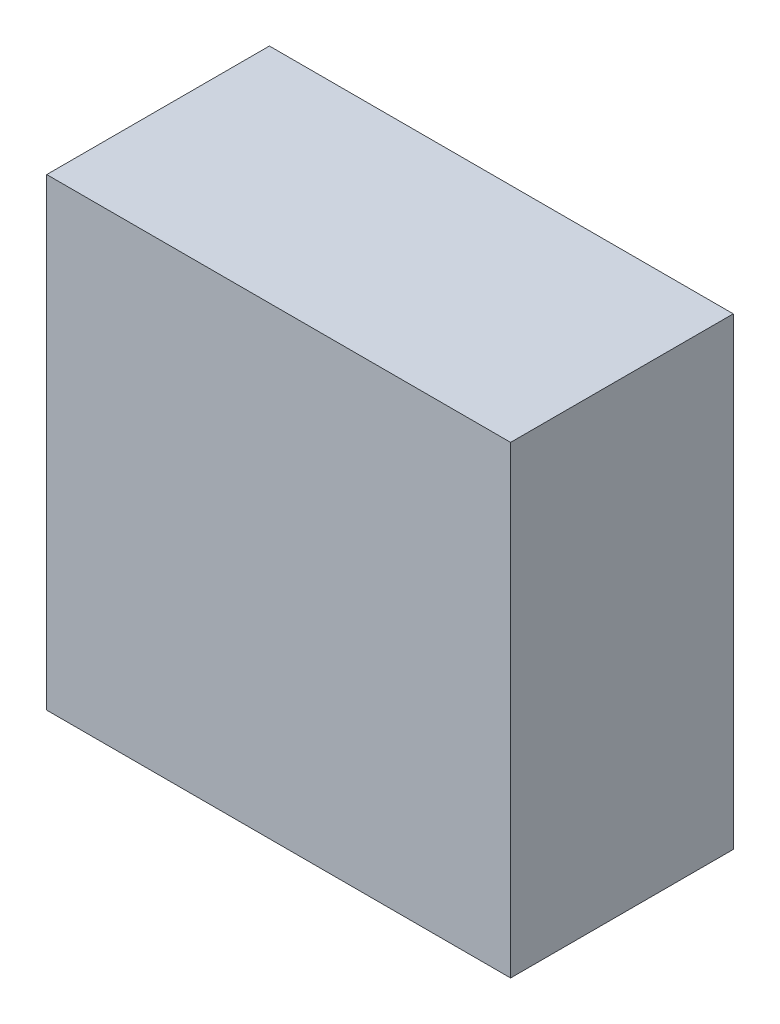
from build123d import *

# Parameters (mm, degrees)
EXTRUDE_1_DEPTH = 6


with BuildPart() as part:
    # 草图1 → 凸台-拉伸1 (new body)
    with BuildSketch(Plane.XY):
        Polygon((104.154385864, 38.646589675), (104.154385864, 44.896589675), (116.654385864, 44.896589675), (116.654385864, 32.396589675), (104.154385864, 32.396589675), align=None)
    extrude(amount=EXTRUDE_1_DEPTH)


solid = part.part
